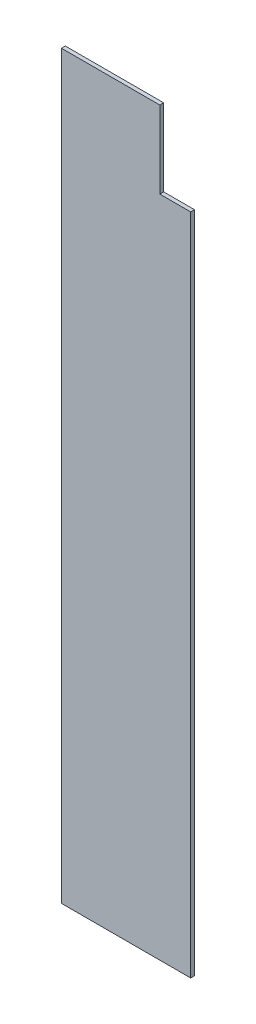
from build123d import *

# Parameters (mm, degrees)
BOSS_EXTRUDE1_DEPTH = 6.35


with BuildPart() as part:
    # Sketch1 → Boss-Extrude1 (new body)
    with BuildSketch(Plane.XY):
        Polygon((168.275, 1219.2), (330.2, 1219.2), (330.2, 1092.2), (381, 1092.2), (381, 0), (168.275, 0), align=None)
    extrude(amount=BOSS_EXTRUDE1_DEPTH)


solid = part.part
